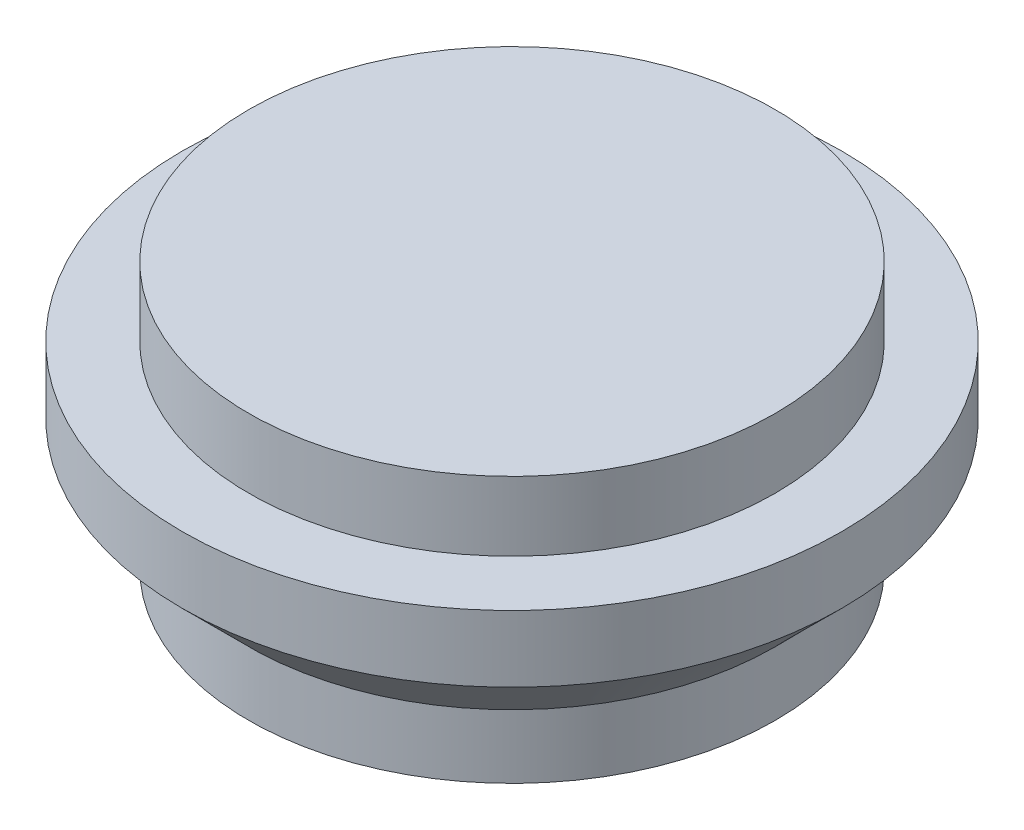
from build123d import *


with BuildPart() as part:
    # Sketch2 → Revolve1 (revolve)
    with BuildSketch(Plane.XY):
        Polygon((11.303, 0), (12.573, 0), (12.573, 3.048), (15.748, 6.223), (15.748, 9.398), (12.573, 9.398), (12.573, 12.7), (0, 12.7), (0, 11.303), align=None)
    revolve(axis=Axis((0, 12.7, 0), (0, -1, 0)))


solid = part.part
